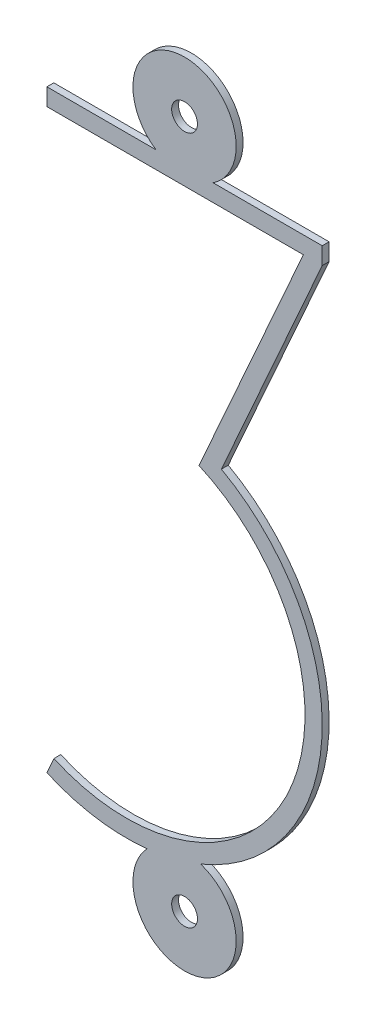
from build123d import *

# Parameters (mm, degrees)
SKETCH1_R           = 0.375
BOSS_EXTRUDE1_DEPTH = 0.1


with BuildPart() as part:
    # Sketch1 → Boss-Extrude1 (new body, symmetric)
    with BuildSketch(Plane.XY):
        with BuildLine():
            Line((-4, 8.75), (-0.829156198, 8.75))
            ThreePointArc((-0.829156198, 8.75), (0, 11.5), (0.829156198, 8.75))
            Line((0.829156198, 8.75), (4, 8.75))
            Line((4, 8.75), (4, 8.25))
            Line((4, 8.25), (1.070800598, 1.663056339))
            ThreePointArc((1.070800598, 1.663056339), (3.990187346, -3.645423064), (0.468669321, -8.575096822))
            ThreePointArc((0.468669321, -8.575096822), (0.367162541, -11.454369853), (-1.088850392, -8.968300032))
            ThreePointArc((-1.088850392, -8.968300032), (-2.57467118, -8.930560768), (-4, -8.509223116))
            Line((-4, -8.509223116), (-3.796834113, -8.052360311))
            ThreePointArc((-3.796834113, -8.052360311), (3.052360311, -5.419717925), (0.419717925, 1.429476498))
            Line((0.419717925, 1.429476498), (3.452789771, 8.25))
            Line((3.452789771, 8.25), (-4, 8.25))
            Line((-4, 8.25), (-4, 8.75))
        make_face()
        with Locations((0, 10)):
            Circle(SKETCH1_R, mode=Mode.SUBTRACT)
        with Locations((0, -10)):
            Circle(SKETCH1_R, mode=Mode.SUBTRACT)
    extrude(amount=BOSS_EXTRUDE1_DEPTH, both=True)


solid = part.part
